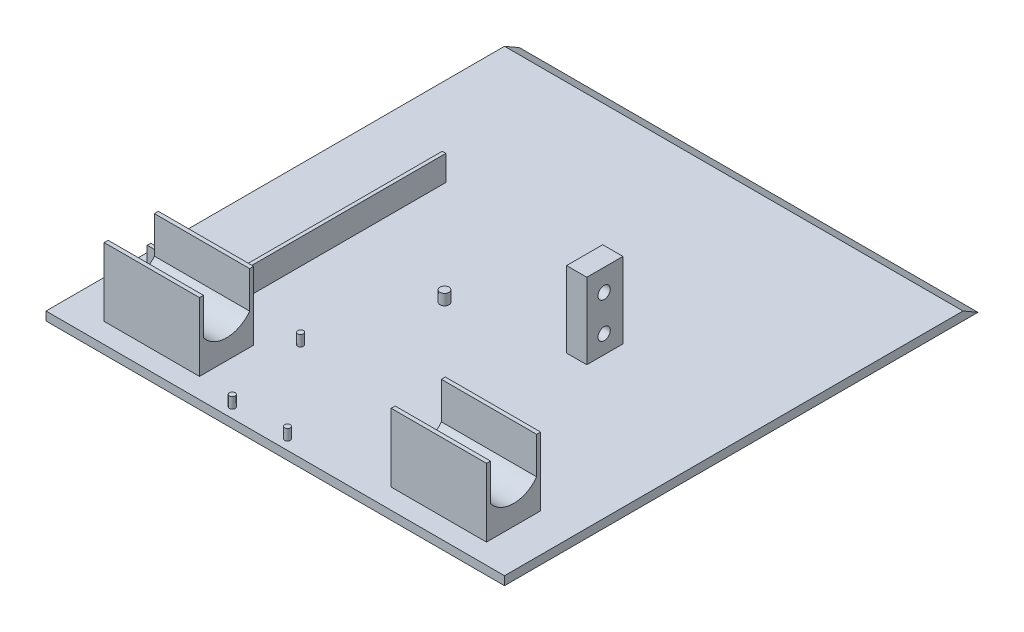
from build123d import *

# Parameters (mm, degrees)
SKETCH1_W                = 127
SKETCH1_H                = 127
BOSS_EXTRUDE1_DEPTH      = 2.4
SKETCH2_W                = 26.4
SKETCH2_H                = 15
BOSS_EXTRUDE3_DEPTH      = 5.5
BOSS_EXTRUDE4_REACH      = 92.149
BOSS_EXTRUDE4_END_RADIUS = 8
SKETCH3_W                = 26.4
SKETCH3_H                = 12.8
SKETCH4_W                = 26.4
SKETCH4_H                = 1.1
BOSS_EXTRUDE5_DEPTH      = 13.40885
BOSS_EXTRUDE8_DEPTH      = 7
SKETCH7_R                = 0.8
BOSS_EXTRUDE9_DEPTH      = 3
SKETCH8_R                = 1.25
BOSS_EXTRUDE10_DEPTH     = 3
SKETCH9_W                = 5.6
SKETCH9_H                = 10
BOSS_EXTRUDE11_DEPTH     = 21
SKETCH10_R               = 1.7
CUT_EXTRUDE1_DEPTH       = 5.6
BOSS_EXTRUDE12_DEPTH     = 127


with BuildPart() as part:
    # Sketch1 → Boss-Extrude1 (new body)
    with BuildSketch(Plane(origin=(0, 0, 0), x_dir=(1, 0, 0), z_dir=(0, 1, 0))):
        Rectangle(SKETCH1_W, SKETCH1_H)
    extrude(amount=BOSS_EXTRUDE1_DEPTH)

    # Sketch2 → Boss-Extrude3 (add)
    with BuildSketch(Plane(origin=(0, 2.4, 0), x_dir=(1, 0, 0), z_dir=(0, 1, 0))):
        with Locations((-39.747989038, -50.434775134)):
            Rectangle(SKETCH2_W, SKETCH2_H)
    boss_extrude3 = extrude(amount=BOSS_EXTRUDE3_DEPTH)

    # Boss-Extrude4: up to this cylinder (the profile starts outside it)
    boss_extrude4_end = Plane(origin=(-39.747989, 15.906072529, 50.434775134), z_dir=(-1, 0, 0)) * Cylinder(BOSS_EXTRUDE4_END_RADIUS, 201.298, mode=Mode.PRIVATE)
    # Sketch3 → Boss-Extrude4 (add, up to the surface)
    with BuildSketch(Plane(origin=(0, 7.9, 0), x_dir=(1, 0, 0), z_dir=(0, 1, 0)), mode=Mode.PRIVATE) as boss_extrude4_sk1:
        with Locations((-39.747989038, -50.434775134)):
            Rectangle(SKETCH3_W, SKETCH3_H)
    boss_extrude4_tool1 = extrude(boss_extrude4_sk1.sketch, amount=BOSS_EXTRUDE4_REACH, mode=Mode.PRIVATE) - boss_extrude4_end
    boss_extrude4 = boss_extrude4_tool1.solids().sort_by_distance((-39.747989, 7.9, 50.434775))[0]
    add(boss_extrude4)

    # Sketch4 → Boss-Extrude5 (add)
    with BuildSketch(Plane(origin=(0, 7.9, 0), x_dir=(1, 0, 0), z_dir=(0, 1, 0))):
        with Locations((-39.747989038, -43.484775134)):
            Rectangle(SKETCH4_W, SKETCH4_H)
        with Locations((-39.747989038, -57.384775134)):
            Rectangle(SKETCH4_W, SKETCH4_H)
    boss_extrude5 = extrude(amount=BOSS_EXTRUDE5_DEPTH)

    # Mirror1: Boss-Extrude3 across plane
    add(boss_extrude3.mirror(Plane(origin=(0, 0, 0), x_dir=(0, 0, 1), z_dir=(1, 0, 0))))

    # Mirror2: Boss-Extrude5 across plane
    add(boss_extrude5.mirror(Plane(origin=(0, 0, 0), x_dir=(0, 0, 1), z_dir=(1, 0, 0))))

    # Mirror3: Boss-Extrude4 across plane
    add(boss_extrude4.mirror(Plane(origin=(0, 0, 0), x_dir=(0, 0, 1), z_dir=(1, 0, 0))))

    # Sketch6 → Boss-Extrude8 (add)
    with BuildSketch(Plane(origin=(0, 2.4, 0), x_dir=(1, 0, 0), z_dir=(0, 1, 0))):
        Polygon((-58.25637406, -39.71881472), (-58.25637406, -40.71881472), (-38.943651891, -40.71881472), (-38.943651891, 22.696046836), (-39.943651891, 22.696046836), (-39.943651891, -39.71881472), align=None)
    extrude(amount=BOSS_EXTRUDE8_DEPTH)

    # Sketch7 → Boss-Extrude9 (add)
    with BuildSketch(Plane(origin=(0, 2.4, 0), x_dir=(1, 0, 0), z_dir=(0, 1, 0))):
        with Locations(Location((-20.157758856, -36.323995409, 0), (0, 0, 90))):
            Circle(SKETCH7_R)
        with Locations(Location((-35.457758856, -36.323995409, 0), (0, 0, 90))):
            Circle(SKETCH7_R)
        with Locations(Location((-14.70070569, -60.698401589, 0), (0, 0, 90))):
            Circle(SKETCH7_R)
        with Locations(Location((0.59929431, -60.698401589, 0), (0, 0, 90))):
            Circle(SKETCH7_R)
    extrude(amount=BOSS_EXTRUDE9_DEPTH)

    # Sketch8 → Boss-Extrude10 (add)
    with BuildSketch(Plane(origin=(0, 2.4, 0), x_dir=(1, 0, 0), z_dir=(0, 1, 0))):
        with Locations(Location((-10.411058541, -6.196769083, 0), (0, 0, 90))):
            Circle(SKETCH8_R)
    extrude(amount=BOSS_EXTRUDE10_DEPTH)

    # Sketch9 → Boss-Extrude11 (add)
    with BuildSketch(Plane(origin=(0, 2.4, 0), x_dir=(1, 0, 0), z_dir=(0, 1, 0))):
        with Locations((21.5, 3.5)):
            Rectangle(SKETCH9_W, SKETCH9_H)
    extrude(amount=BOSS_EXTRUDE11_DEPTH)

    # Sketch10 → Cut-Extrude1 (cut)
    with BuildSketch(Plane(origin=(24.3, 0, 0), x_dir=(0, 0, -1), z_dir=(1, 0, 0))):
        with Locations((3.3, 17.35)):
            Circle(SKETCH10_R)
        with Locations((3.3, 7.45)):
            Circle(SKETCH10_R)
    extrude(amount=-CUT_EXTRUDE1_DEPTH, mode=Mode.SUBTRACT)

    # Sketch11 → Boss-Extrude12 (add)
    with BuildSketch(Plane(origin=(63.5, 0, 0), x_dir=(0, 0, -1), z_dir=(1, 0, 0))):
        Polygon((63.5, 2.4), (67.656921938, 0), (63.5, 0), align=None)
    extrude(amount=-BOSS_EXTRUDE12_DEPTH)


solid = part.part
